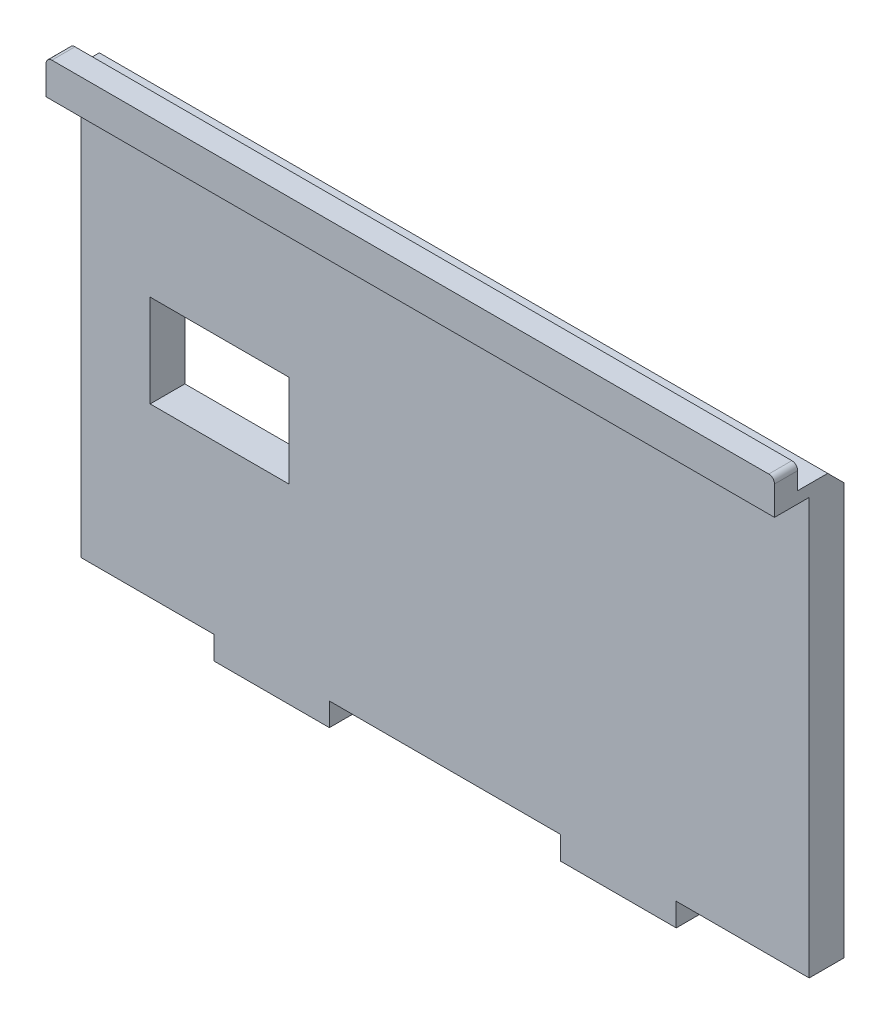
from build123d import *

# Parameters (mm, degrees)
SKETCH1_W           = 63
SKETCH1_H           = 37
BOSS_EXTRUDE1_DEPTH = 3
SKETCH2_W           = 10
SKETCH2_H           = 2
BOSS_EXTRUDE2_DEPTH = 2
SKETCH3_W           = 63
SKETCH3_H           = 1
BOSS_EXTRUDE3_DEPTH = 3
SKETCH4_W           = 12
SKETCH4_H           = 8
CUT_EXTRUDE1_DEPTH  = 4
SKETCH5_W           = 63
SKETCH5_H           = 2
BOSS_EXTRUDE4_DEPTH = 2
CHAMFER1_SIZE       = 1.4
FILLET1_R           = 0.5


with BuildPart() as part:
    # Sketch1 → Boss-Extrude1 (new body)
    with BuildSketch(Plane.XY):
        Rectangle(SKETCH1_W, SKETCH1_H)
    extrude(amount=BOSS_EXTRUDE1_DEPTH)

    # Sketch2 → Boss-Extrude2 (add)
    with BuildSketch(Plane.XZ.offset(18.5)):
        with Locations((-15, 2)):
            Rectangle(SKETCH2_W, SKETCH2_H)
        with Locations((15, 2)):
            Rectangle(SKETCH2_W, SKETCH2_H)
    extrude(amount=BOSS_EXTRUDE2_DEPTH)

    # Sketch3 → Boss-Extrude3 (add)
    with BuildSketch(Plane.XY.offset(3)):
        with Locations((0, 18)):
            Rectangle(SKETCH3_W, SKETCH3_H)
    extrude(amount=BOSS_EXTRUDE3_DEPTH)

    # Sketch4 → Cut-Extrude1 (cut, through all)
    with BuildSketch(Plane.XY.offset(3)):
        with Locations((-19.5, 0)):
            Rectangle(SKETCH4_W, SKETCH4_H)
    extrude(amount=-CUT_EXTRUDE1_DEPTH, mode=Mode.SUBTRACT)

    # Sketch5 → Boss-Extrude4 (add)
    with BuildSketch(Plane(origin=(0, 18.5, 0), x_dir=(1, 0, 0), z_dir=(0, 1, 0))):
        with Locations((0, -5)):
            Rectangle(SKETCH5_W, SKETCH5_H)
    extrude(amount=BOSS_EXTRUDE4_DEPTH)

    # Chamfer1
    chamfer1_edges = [part.edges().sort_by_distance(p)[0] for p in [
        (0, 18.5, 0),
    ]]
    chamfer(chamfer1_edges, length=CHAMFER1_SIZE)

    # Fillet1
    fillet1_edges = [part.edges().sort_by_distance(p)[0] for p in [
        (31.5, 20.5, 5),
        (-31.5, 20.5, 5),
    ]]
    fillet(fillet1_edges, radius=FILLET1_R)


solid = part.part
